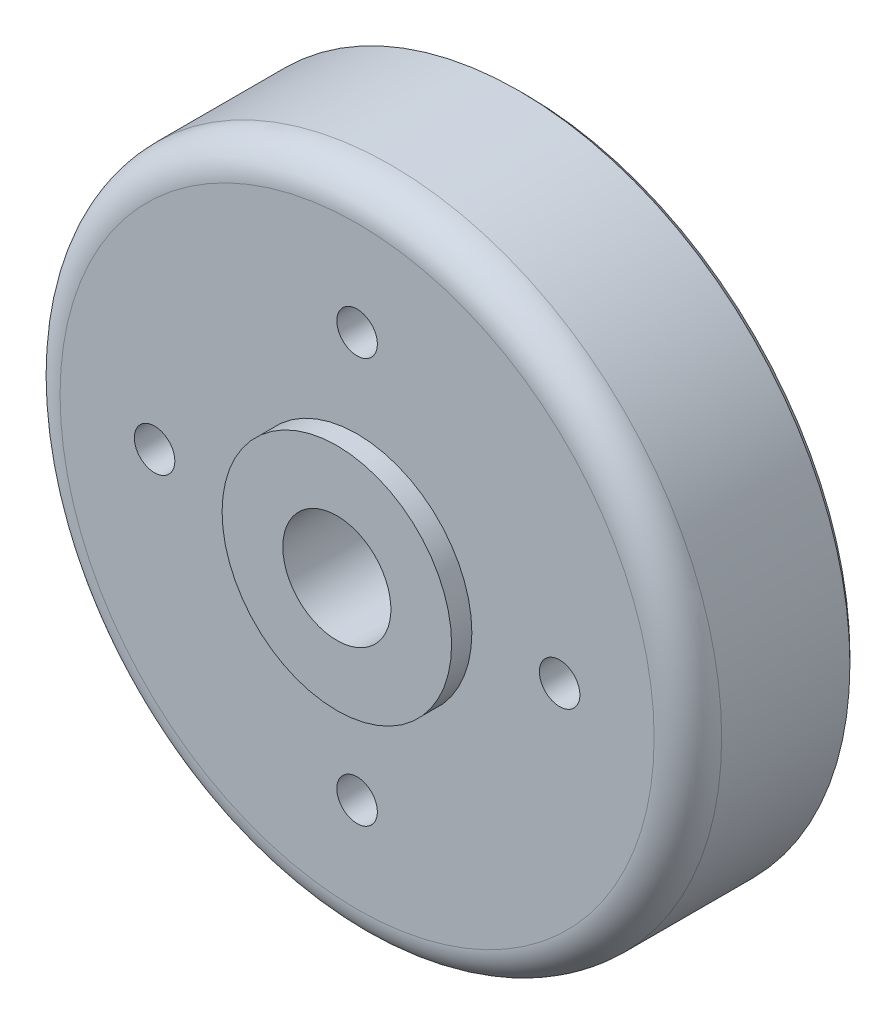
from build123d import *

# Parameters (mm, degrees)
SKETCH2_R          = 8000
CUT_EXTRUDE1_DEPTH = 50000
SKETCH4_R          = 3000
CUT_EXTRUDE2_DEPTH = 50000
FILLET3_R          = 5000
FILLET4_R          = 2000
FILLET5_R          = 2000
CHAMFER1_SIZE      = 1000


with BuildPart() as part:
    # Sketch1 → Revolve1 (revolve)
    with BuildSketch(Plane(origin=(0, 0, 0), x_dir=(1, 0, 0), z_dir=(0, 1, 0))):
        Polygon((0, -29166.666666667), (17000, -29166.666666667), (17000, -26166.666666667), (49000, -26166.666666667), (49000, -1166.666666667), (45000, -1166.666666667), (43000, -16166.666666667), (17000, -16166.666666667), (14000, 14833.333333333), (0, 14833.333333333), align=None)
    revolve(axis=Axis((0, 0, -29842.077171976), (0, 0, 1)))

    # Sketch2 → Cut-Extrude1 (cut)
    with BuildSketch(Plane(origin=(0, 0, -14833.333333333), x_dir=(-1, 0, 0), z_dir=(0, 0, -1))):
        Circle(SKETCH2_R)
    extrude(amount=-CUT_EXTRUDE1_DEPTH, mode=Mode.SUBTRACT)

    # Sketch4 → Cut-Extrude2 (cut)
    with BuildSketch(Plane.XY.offset(26166.666666667)):
        with Locations((0, 30000)):
            Circle(SKETCH4_R)
        with Locations((30000, 0)):
            Circle(SKETCH4_R)
        with Locations((0, -30000)):
            Circle(SKETCH4_R)
        with Locations((-30000, 0)):
            Circle(SKETCH4_R)
    extrude(amount=-CUT_EXTRUDE2_DEPTH, mode=Mode.SUBTRACT)

    # Fillet3
    fillet3_edges = [part.edges().sort_by_distance(p)[0] for p in [
        (-49000, 0, 26166.666666667),
    ]]
    fillet(fillet3_edges, radius=FILLET3_R)

    # Fillet4
    fillet4_edges = [part.edges().sort_by_distance(p)[0] for p in [
        (-43000, 0, 16166.666666667),
    ]]
    fillet(fillet4_edges, radius=FILLET4_R)

    # Fillet5
    fillet5_edges = [part.edges().sort_by_distance(p)[0] for p in [
        (-14000, 0, -14833.333333333),
    ]]
    fillet(fillet5_edges, radius=FILLET5_R)

    # Chamfer1
    chamfer1_edges = [part.edges().sort_by_distance(p)[0] for p in [
        (-49000, 0, 1166.666666667),
    ]]
    chamfer(chamfer1_edges, length=CHAMFER1_SIZE)


solid = part.part
